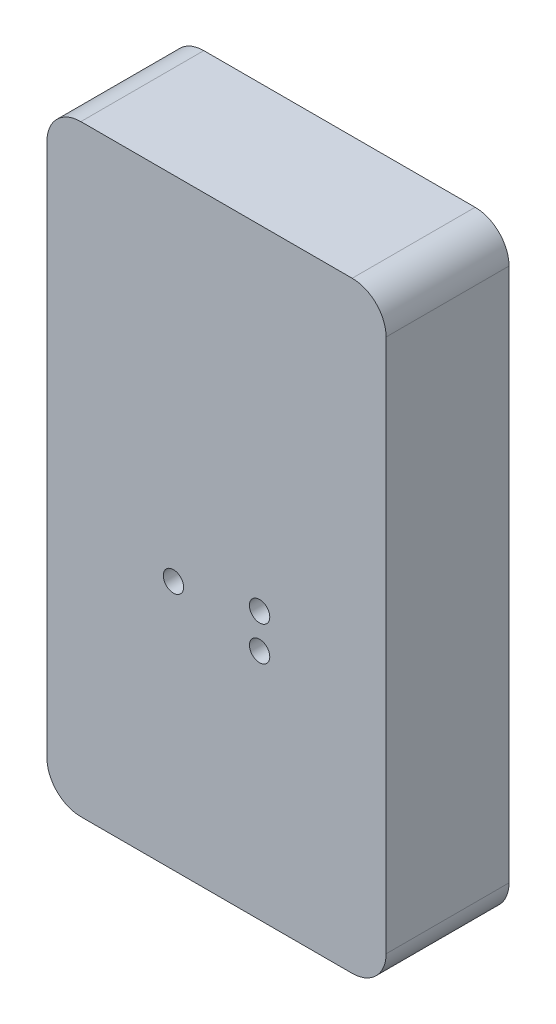
from build123d import *

# Parameters (mm, degrees)
SKETCH1_W           = 20
SKETCH1_H           = 35.5
BOSS_EXTRUDE1_DEPTH = 7.25
CUT_EXTRUDE1_DEPTH  = 5.75
SKETCH3_R           = 0.6
CUT_EXTRUDE2_DEPTH  = 7.25
FILLET1_R           = 2
SKETCH4_W           = 2.378205128
SKETCH4_H           = 0.583333334
CUT_EXTRUDE3_DEPTH  = 1
CHAMFER1_SIZE       = 0.5


with BuildPart() as part:
    # Sketch1 → Boss-Extrude1 (new body)
    with BuildSketch(Plane.XY):
        Rectangle(SKETCH1_W, SKETCH1_H)
    extrude(amount=BOSS_EXTRUDE1_DEPTH)

    # Sketch2 → Cut-Extrude1 (cut)
    with BuildSketch(Plane.XY):
        Polygon((-3.625, 11.125), (-3.625, 16.125), (3.625, 16.125), (3.625, 11.125), (8.375, 11.125), (8.375, -11.125), (3.625, -11.125), (3.625, -16.125), (-3.625, -16.125), (-3.625, -11.125), (-8.375, -11.125), (-8.375, 11.125), align=None)
    extrude(amount=CUT_EXTRUDE1_DEPTH, mode=Mode.SUBTRACT)

    # Sketch3 → Cut-Extrude2 (cut)
    with BuildSketch(Plane.XY):
        with Locations((-2.54, -3)):
            Circle(SKETCH3_R)
        with Locations((2.54, -1.984)):
            Circle(SKETCH3_R)
        with Locations((2.54, -4.016)):
            Circle(SKETCH3_R)
    extrude(amount=CUT_EXTRUDE2_DEPTH, mode=Mode.SUBTRACT)

    # Fillet1
    fillet1_edges = [part.edges().sort_by_distance(p)[0] for p in [
        (10, -17.75, 3.625),
        (-10, -17.75, 3.625),
        (-10, 17.75, 3.625),
        (10, 17.75, 3.625),
    ]]
    fillet(fillet1_edges, radius=FILLET1_R)

    # Sketch4 → Cut-Extrude3 (cut)
    with BuildSketch(Plane.XY):
        Polygon((-6.498397436, 14.474358974), (-6.498397436, 15.326923077), (-7.081730769, 15.326923077), (-7.081730769, 14.474358974), (-7.979166667, 14.474358974), (-7.979166667, 13.891025641), (-7.081730769, 13.891025641), (-7.081730769, 13.038461538), (-6.498397436, 13.038461538), (-6.498397436, 13.891025641), (-5.600961538, 13.891025641), (-5.600961538, 14.474358974), align=None)
        with Locations((6.716346154, -14.278846154)):
            Rectangle(SKETCH4_W, SKETCH4_H)
    extrude(amount=CUT_EXTRUDE3_DEPTH, mode=Mode.SUBTRACT)

    # Chamfer1
    chamfer1_edges = [part.edges().sort_by_distance(p)[0] for p in [
        (3.625, 13.625, 0),
        (0, 16.125, 0),
        (-3.625, 13.625, 0),
        (-6, 11.125, 0),
        (-8.375, 0, 0),
        (-6, -11.125, 0),
        (-3.625, -13.625, 0),
        (0, -16.125, 0),
        (3.625, -13.625, 0),
        (6, -11.125, 0),
        (8.375, 0, 0),
        (6, 11.125, 0),
    ]]
    chamfer(chamfer1_edges, length=CHAMFER1_SIZE)


solid = part.part
